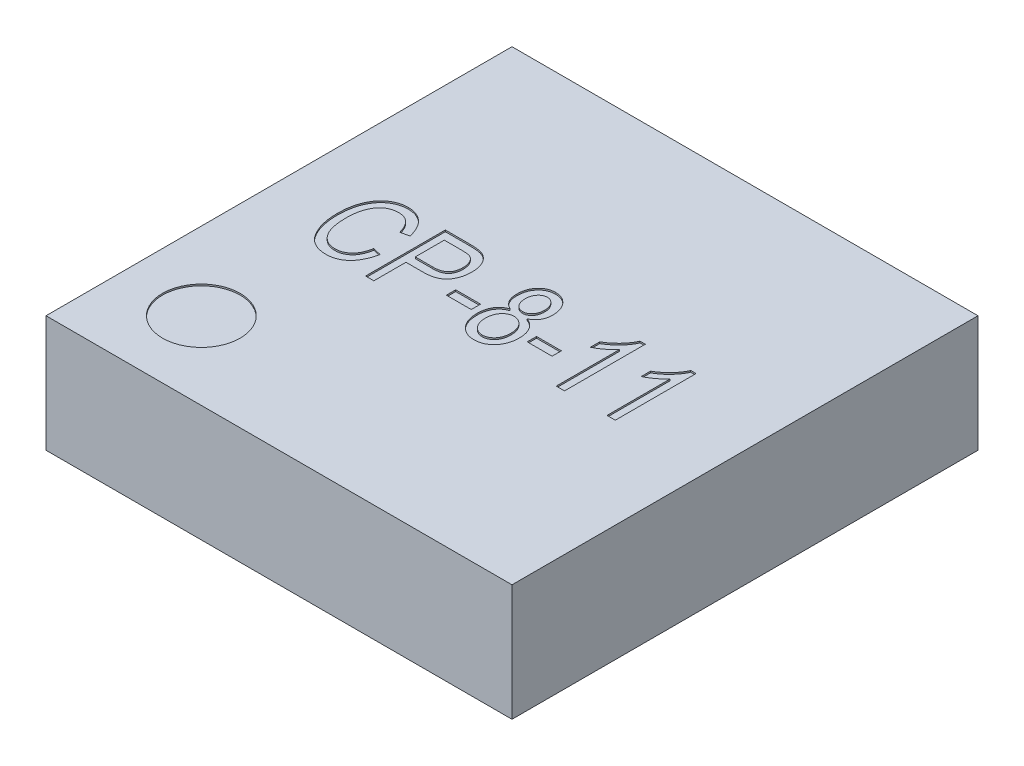
from build123d import *

# Parameters (mm, degrees)
SKETCH1_W           = 3
SKETCH1_H           = 3
BOSS_EXTRUDE1_DEPTH = 0.75
SKETCH2_R           = 0.25
CUT_EXTRUDE1_DEPTH  = 0.01
SKETCH5_W           = 0.160102983
SKETCH5_H           = 0.060038619
CUT_EXTRUDE3_DEPTH  = 0.01


with BuildPart() as part:
    # Sketch1 → Boss-Extrude1 (new body)
    with BuildSketch(Plane(origin=(0, 0, 0), x_dir=(1, 0, 0), z_dir=(0, 1, 0))):
        Rectangle(SKETCH1_W, SKETCH1_H)
    extrude(amount=BOSS_EXTRUDE1_DEPTH)

    # Sketch2 → Cut-Extrude1 (cut)
    with BuildSketch(Plane(origin=(0, 0.75, 0), x_dir=(1, 0, 0), z_dir=(0, 1, 0))):
        with Locations(Location((-1, -1, 0), (0, 0, 270))):
            Circle(SKETCH2_R)
    extrude(amount=-CUT_EXTRUDE1_DEPTH, mode=Mode.SUBTRACT)

    # Sketch5 → Cut-Extrude3 (cut)
    with BuildSketch(Plane(origin=(0, 0.75, 0), x_dir=(1, 0, 0), z_dir=(0, 1, 0))):
        with BuildLine():
            Line((-0.819562322, -0.069884144), (-0.766194661, -0.083226059))
            add(Edge.make_bspline(
                [(-0.766194661, -0.083226059), (-0.767785294, -0.090298254), (-0.770886363, -0.104086083), (-0.776702946, -0.123917486), (-0.783499751, -0.142322568), (-0.791090653, -0.159371055), (-0.799536523, -0.175065562), (-0.808795785, -0.189395293), (-0.818946382, -0.202348536), (-0.830038875, -0.213765782), (-0.841702978, -0.224010076), (-0.85421037, -0.232609166), (-0.86718476, -0.240145481), (-0.880874045, -0.246147831), (-0.895140051, -0.250901973), (-0.91005958, -0.254181603), (-0.925572015, -0.256379357), (-0.936157368, -0.256572956), (-0.941515766, -0.256670958)],
                knots=[0, 0, 0, 0, 1.289221957, 2.51344498, 3.673011535, 4.776835723, 5.830430132, 6.840130389, 7.808269491, 8.7523986, 9.668123701, 10.564817631, 11.447926293, 12.333367568, 13.218722559, 14.118350969, 15.047492789, 16, 16, 16, 16], degree=3))
            add(Edge.make_bspline(
                [(-0.941515766, -0.256670958), (-0.946245001, -0.256605701), (-0.955515411, -0.256477783), (-0.969158098, -0.255031745), (-0.982309097, -0.252919536), (-0.994937963, -0.249739562), (-1.007072515, -0.24584663), (-1.018595594, -0.240846974), (-1.029694441, -0.235157022), (-1.040242021, -0.228432663), (-1.050363647, -0.220814832), (-1.059787685, -0.211957525), (-1.068969987, -0.20227548), (-1.077440003, -0.191306057), (-1.085772683, -0.179486592), (-1.093263877, -0.166375155), (-1.100531229, -0.152355342), (-1.107223863, -0.137314422), (-1.113457604, -0.121403643), (-1.118548257, -0.104599383), (-1.123088544, -0.087194103), (-1.126691944, -0.069052902), (-1.129665056, -0.05025115), (-1.131547806, -0.030686803), (-1.132878496, -0.010454576), (-1.13302357, 0.003285615), (-1.133097331, 0.010271581)],
                knots=[0, 0, 0, 0, 0.921095259, 1.805562833, 2.670327692, 3.514278933, 4.340642213, 5.150451062, 5.958900505, 6.768369716, 7.58482939, 8.423223242, 9.285360719, 10.181948201, 11.120907027, 12.10087379, 13.121233649, 14.196976745, 15.307105309, 16.44839936, 17.61583717, 18.810746038, 20.050660639, 21.323136918, 22.638994396, 24, 24, 24, 24], degree=3))
            add(Edge.make_bspline(
                [(-1.133097331, 0.010271581), (-1.133024173, 0.017153383), (-1.132880687, 0.030650741), (-1.131552175, 0.05046653), (-1.129674216, 0.069512125), (-1.126690629, 0.087722158), (-1.123111878, 0.105175868), (-1.118588539, 0.121757099), (-1.11342171, 0.137602263), (-1.10727773, 0.152559829), (-1.100354257, 0.166641718), (-1.092955946, 0.179906524), (-1.085065647, 0.192355451), (-1.076502762, 0.203860971), (-1.067313005, 0.214394517), (-1.057570963, 0.224061575), (-1.047226048, 0.232802019), (-1.036397959, 0.240774009), (-1.02505111, 0.247683272), (-1.01341952, 0.253819084), (-1.001415684, 0.258910155), (-0.989083411, 0.263093701), (-0.976434622, 0.266345693), (-0.96346455, 0.268581594), (-0.950205858, 0.270158631), (-0.941242525, 0.27027566), (-0.936721016, 0.270334695)],
                knots=[0, 0, 0, 0, 1.355009242, 2.657595594, 3.909622363, 5.12221665, 6.289669639, 7.416642245, 8.504963989, 9.569716403, 10.597874851, 11.593392335, 12.559484071, 13.498222117, 14.414780627, 15.309839368, 16.198178116, 17.079506653, 17.954919271, 18.811820418, 19.667108407, 20.519600343, 21.37423126, 22.235899437, 23.110108003, 24, 24, 24, 24], degree=3))
            add(Edge.make_bspline(
                [(-0.936721016, 0.270334695), (-0.931782876, 0.270206847), (-0.922082694, 0.269955711), (-0.907755076, 0.268197066), (-0.894049104, 0.2649985), (-0.880734222, 0.260877676), (-0.868060298, 0.255307035), (-0.85586358, 0.248605142), (-0.844250446, 0.240630738), (-0.833213313, 0.23143294), (-0.822764165, 0.221125603), (-0.81313969, 0.20960075), (-0.804427749, 0.196909476), (-0.796289764, 0.183229479), (-0.789280602, 0.168227328), (-0.7829609, 0.15216685), (-0.777206964, 0.135020621), (-0.774337034, 0.123043399), (-0.772865619, 0.116902669)],
                knots=[0, 0, 0, 0, 0.969230344, 1.90389736, 2.827024372, 3.728538081, 4.635631584, 5.539103428, 6.456494714, 7.396000419, 8.355610671, 9.333534695, 10.338037519, 11.374284513, 12.454112223, 13.583699076, 14.761161004, 16, 16, 16, 16], degree=3))
            Line((-0.772865619, 0.116902669), (-0.82623328, 0.103560754))
            add(Edge.make_bspline(
                [(-0.82623328, 0.103560754), (-0.827439498, 0.107882608), (-0.829791985, 0.116311523), (-0.833978303, 0.128418013), (-0.838556982, 0.139697907), (-0.843533126, 0.150181656), (-0.849074465, 0.159778289), (-0.855019042, 0.168566011), (-0.86137703, 0.176569284), (-0.868281976, 0.183619353), (-0.875504072, 0.189980484), (-0.883264627, 0.195429784), (-0.891499204, 0.19998217), (-0.900133395, 0.203809004), (-0.909194482, 0.206687466), (-0.918712261, 0.208807665), (-0.928661435, 0.210058267), (-0.935466728, 0.210216179), (-0.938909924, 0.210296076)],
                knots=[0, 0, 0, 0, 1.274827499, 2.486296693, 3.637698816, 4.732866786, 5.781146847, 6.783409552, 7.745577291, 8.681189198, 9.583979081, 10.476943643, 11.369744444, 12.253932728, 13.156290603, 14.066553906, 15.021756508, 16, 16, 16, 16], degree=3))
            add(Edge.make_bspline(
                [(-0.938909924, 0.210296076), (-0.945706113, 0.210044284), (-0.958967845, 0.20955295), (-0.978148328, 0.205465966), (-0.995994685, 0.19892868), (-1.00957763, 0.191084332), (-1.019648576, 0.18356043), (-1.026787039, 0.177128071), (-1.033508527, 0.169947158), (-1.039894865, 0.162086071), (-1.045944345, 0.153480514), (-1.051399698, 0.144025722), (-1.05669042, 0.133989925), (-1.061457926, 0.123158901), (-1.065705133, 0.111592205), (-1.069482771, 0.099314869), (-1.072704686, 0.086305165), (-1.075303635, 0.072523495), (-1.077236038, 0.058008824), (-1.07872591, 0.042749213), (-1.07952591, 0.026749103), (-1.079660916, 0.015831496), (-1.07972967, 0.010271581)],
                knots=[0, 0, 0, 0, 1.477189771, 2.882511776, 4.245778241, 5.596752156, 6.277022015, 6.978177212, 7.684002091, 8.414723124, 9.180080371, 9.969542299, 10.787683758, 11.647234596, 12.541638645, 13.466905688, 14.440346501, 15.45581228, 16.516221105, 17.624831929, 18.790418795, 20, 20, 20, 20], degree=3))
            add(Edge.make_bspline(
                [(-1.07972967, 0.010271581), (-1.079597837, 0.001930269), (-1.079342139, -0.014248321), (-1.077711704, -0.037744912), (-1.074859166, -0.059657866), (-1.070671638, -0.079914137), (-1.065499151, -0.098578906), (-1.059206021, -0.115659314), (-1.0515537, -0.13108365), (-1.042811289, -0.144883999), (-1.033056819, -0.157050404), (-1.022532334, -0.167650607), (-1.011171414, -0.176576314), (-0.999112043, -0.183997784), (-0.986174661, -0.189611283), (-0.972540921, -0.193717459), (-0.958106251, -0.196153283), (-0.94823078, -0.196470309), (-0.943183506, -0.196632339)],
                knots=[0, 0, 0, 0, 1.437104972, 2.787371166, 4.055570009, 5.241294904, 6.348053785, 7.389870239, 8.372351441, 9.308936623, 10.198930124, 11.053953419, 11.87666206, 12.682560998, 13.486679433, 14.299132302, 15.130700221, 16, 16, 16, 16], degree=3))
            add(Edge.make_bspline(
                [(-0.943183506, -0.196632339), (-0.939425994, -0.196528996), (-0.932021406, -0.196325347), (-0.921105015, -0.194804129), (-0.910545955, -0.192451887), (-0.90037098, -0.188999631), (-0.890689676, -0.184449319), (-0.881306686, -0.179151576), (-0.87241586, -0.172695918), (-0.863892883, -0.16535142), (-0.855913064, -0.156951235), (-0.848618087, -0.147504172), (-0.841897901, -0.137087218), (-0.836132852, -0.125528209), (-0.830890515, -0.113069368), (-0.826314247, -0.099595857), (-0.822450941, -0.085107751), (-0.820540679, -0.075040282), (-0.819562322, -0.069884144)],
                knots=[0, 0, 0, 0, 0.928044623, 1.828813311, 2.717973564, 3.597468745, 4.476963925, 5.35746386, 6.25552913, 7.186585864, 8.133765821, 9.112470931, 10.131597503, 11.191133367, 12.299110282, 13.469062082, 14.703759174, 16, 16, 16, 16], degree=3))
        make_face()
        with BuildLine():
            Line((-0.692814128, -0.25), (-0.692814128, 0.263663737))
            Line((-0.692814128, 0.263663737), (-0.534587351, 0.263663737))
            add(Edge.make_bspline(
                [(-0.534587351, 0.263663737), (-0.530069601, 0.263667976), (-0.521378123, 0.263676132), (-0.508802339, 0.263060869), (-0.497110496, 0.262439162), (-0.486343609, 0.26123954), (-0.476493529, 0.259929597), (-0.467570318, 0.258292664), (-0.459572194, 0.256223859), (-0.454597101, 0.254552485), (-0.452242718, 0.253761534)],
                knots=[0, 0, 0, 0, 1.301145482, 2.503209419, 3.626350361, 4.67304202, 5.622796861, 6.488461115, 7.284688674, 8, 8, 8, 8], degree=3))
            add(Edge.make_bspline(
                [(-0.452242718, 0.253761534), (-0.44926147, 0.252607629), (-0.443306037, 0.250302552), (-0.434917469, 0.245751859), (-0.426915349, 0.240625047), (-0.419390368, 0.234788548), (-0.412386658, 0.228152405), (-0.40579459, 0.220862428), (-0.399745133, 0.212768753), (-0.394171393, 0.204043766), (-0.388981379, 0.194775492), (-0.384696175, 0.184850595), (-0.380846787, 0.174478327), (-0.37791799, 0.163537202), (-0.375442878, 0.152104614), (-0.373866427, 0.140145913), (-0.372742828, 0.127660182), (-0.372653733, 0.119163794), (-0.372608162, 0.114817995)],
                knots=[0, 0, 0, 0, 0.897158766, 1.79219156, 2.674738776, 3.564969572, 4.462552928, 5.381685756, 6.322532571, 7.297145314, 8.28871417, 9.302465757, 10.330585605, 11.393732126, 12.480975679, 13.614163778, 14.779673607, 16, 16, 16, 16], degree=3))
            add(Edge.make_bspline(
                [(-0.372608162, 0.114817995), (-0.372696397, 0.109115783), (-0.372868965, 0.097963593), (-0.374563313, 0.081652153), (-0.377379265, 0.066186591), (-0.381221332, 0.05149261), (-0.386211164, 0.037592399), (-0.392389974, 0.024522487), (-0.399638444, 0.012236066), (-0.407913616, 0.000710211), (-0.417665111, -0.009781098), (-0.429173782, -0.018756336), (-0.442194822, -0.026432521), (-0.45689078, -0.032533888), (-0.473111749, -0.037462143), (-0.491004785, -0.040821802), (-0.510500753, -0.042767667), (-0.524020345, -0.043052402), (-0.531043405, -0.043200314)],
                knots=[0, 0, 0, 0, 1.066125632, 2.085091685, 3.062630143, 4.003547869, 4.922307223, 5.820454748, 6.703048758, 7.586837887, 8.469431897, 9.371589709, 10.306565591, 11.287746888, 12.340181319, 13.471797101, 14.68666727, 16, 16, 16, 16], degree=3))
            Line((-0.531043405, -0.043200314), (-0.639446467, -0.043200314))
            Line((-0.639446467, -0.043200314), (-0.639446467, -0.25))
            Line((-0.639446467, -0.25), (-0.692814128, -0.25))
        make_face()
        with BuildLine():
            Line((-0.639446467, 0.016838305), (-0.527707926, 0.016838305))
            add(Edge.make_bspline(
                [(-0.527707926, 0.016838305), (-0.523467507, 0.016933574), (-0.515251648, 0.017118158), (-0.503326673, 0.01810269), (-0.492280679, 0.019980416), (-0.482117246, 0.022551845), (-0.472864666, 0.025904995), (-0.464476781, 0.02993703), (-0.457001483, 0.034790043), (-0.450321013, 0.040337016), (-0.444627221, 0.046781983), (-0.439505402, 0.053802467), (-0.435351732, 0.061729966), (-0.43195731, 0.070376369), (-0.429200101, 0.079713485), (-0.427380875, 0.089813797), (-0.426218043, 0.100649802), (-0.426058167, 0.108143857), (-0.425975823, 0.112003685)],
                knots=[0, 0, 0, 0, 1.269306236, 2.459294321, 3.577321076, 4.618943517, 5.592639886, 6.518111891, 7.397820391, 8.253919533, 9.107995395, 9.965041305, 10.848919063, 11.777714976, 12.741869721, 13.757527659, 14.845010431, 16, 16, 16, 16], degree=3))
            add(Edge.make_bspline(
                [(-0.425975823, 0.112003685), (-0.426094373, 0.117017315), (-0.426323775, 0.126718978), (-0.428696642, 0.140673852), (-0.432367221, 0.153546898), (-0.437739352, 0.165079173), (-0.444021996, 0.175191851), (-0.450901449, 0.183842516), (-0.458584935, 0.190638882), (-0.465735721, 0.194874882), (-0.472015677, 0.197546439), (-0.477611972, 0.199195078), (-0.484074088, 0.200490041), (-0.4913787, 0.201624028), (-0.49951158, 0.202580201), (-0.508488246, 0.203143554), (-0.518322136, 0.203605847), (-0.525170902, 0.203618503), (-0.528750264, 0.203625118)],
                knots=[0, 0, 0, 0, 1.500314686, 2.903195123, 4.226916567, 5.498136997, 6.699407891, 7.786731959, 8.797026544, 9.75363827, 10.261964553, 10.838097333, 11.497334866, 12.234733717, 13.051831226, 13.948971176, 14.928073425, 16, 16, 16, 16], degree=3))
            Line((-0.528750264, 0.203625118), (-0.639446467, 0.203625118))
            Line((-0.639446467, 0.203625118), (-0.639446467, 0.016838305))
        make_face(mode=Mode.SUBTRACT)
        with Locations((-0.245859967, -0.066548665)):
            Rectangle(SKETCH5_W, SKETCH5_H)
        with BuildLine():
            add(Edge.make_bspline(
                [(-0.043333863, 0.03184796), (-0.048244191, 0.034315549), (-0.057824326, 0.039129858), (-0.070593555, 0.048559692), (-0.081481963, 0.059510796), (-0.09045116, 0.072062053), (-0.097390633, 0.086225699), (-0.102215422, 0.101952005), (-0.10535262, 0.11921048), (-0.105627167, 0.131272172), (-0.105769857, 0.137540944)],
                knots=[0, 0, 0, 0, 1.008302473, 1.967215395, 2.901654035, 3.835241807, 4.788827276, 5.786238528, 6.849451133, 8, 8, 8, 8], degree=3))
            add(Edge.make_bspline(
                [(-0.105769857, 0.137540944), (-0.1056743, 0.142339941), (-0.1054875, 0.151721268), (-0.103893199, 0.165461026), (-0.101274719, 0.178486042), (-0.097808052, 0.190892056), (-0.093012142, 0.202490323), (-0.087420075, 0.213555058), (-0.080594864, 0.223840095), (-0.07292235, 0.233438967), (-0.064407353, 0.242038785), (-0.05530628, 0.249598115), (-0.045648399, 0.25603634), (-0.035413013, 0.261226696), (-0.024694255, 0.265335322), (-0.013449479, 0.268295765), (-0.001653462, 0.269926313), (0.006380954, 0.270197385), (0.010450733, 0.270334695)],
                knots=[0, 0, 0, 0, 1.165528948, 2.278436123, 3.35437051, 4.390847764, 5.401785756, 6.398351761, 7.397951243, 8.394481506, 9.379254266, 10.332413116, 11.264104055, 12.192693114, 13.114390379, 14.047914605, 15.011184464, 16, 16, 16, 16], degree=3))
            add(Edge.make_bspline(
                [(0.010450733, 0.270334695), (0.014556848, 0.270209136), (0.022668578, 0.269961093), (0.034549433, 0.268159785), (0.045903617, 0.265231238), (0.056731248, 0.261161008), (0.067015039, 0.255800692), (0.07668879, 0.249201227), (0.085872332, 0.241484791), (0.094443173, 0.232701684), (0.10222242, 0.222952747), (0.109003342, 0.212449218), (0.114934459, 0.201381204), (0.119596868, 0.189504019), (0.123258317, 0.176943318), (0.125824876, 0.163683864), (0.127430097, 0.149775798), (0.127617935, 0.140290228), (0.12771366, 0.13545627)],
                knots=[0, 0, 0, 0, 0.985268531, 1.946421878, 2.87680472, 3.795226773, 4.71648376, 5.65319809, 6.600248485, 7.590936614, 8.593729089, 9.588305238, 10.588007114, 11.602279753, 12.644649782, 13.724021809, 14.840134863, 16, 16, 16, 16], degree=3))
            add(Edge.make_bspline(
                [(0.12771366, 0.13545627), (0.127561336, 0.129431324), (0.12726792, 0.117825637), (0.124241646, 0.101158347), (0.119530444, 0.085877807), (0.112671033, 0.07207018), (0.103902812, 0.059663636), (0.093134777, 0.048779631), (0.080475046, 0.039175288), (0.070856779, 0.034338868), (0.065903068, 0.03184796)],
                knots=[0, 0, 0, 0, 1.126288406, 2.16953834, 3.158564267, 4.109347243, 5.041996175, 5.989081932, 6.964313779, 8, 8, 8, 8], degree=3))
            add(Edge.make_bspline(
                [(0.065903068, 0.03184796), (0.069123331, 0.030545264), (0.075500175, 0.027965633), (0.084530664, 0.023233081), (0.093049947, 0.018047429), (0.100870074, 0.012143924), (0.108224891, 0.005775054), (0.115017752, -0.001211453), (0.121166066, -0.008837204), (0.126679708, -0.017030002), (0.13176814, -0.025669413), (0.135952969, -0.034973246), (0.13967402, -0.04469225), (0.142547409, -0.054963566), (0.144850426, -0.065720602), (0.146480178, -0.076968353), (0.14758979, -0.088728265), (0.147680221, -0.096739001), (0.147726533, -0.100841557)],
                knots=[0, 0, 0, 0, 0.998518868, 1.977292132, 2.928488769, 3.863806314, 4.791620617, 5.724425947, 6.662355446, 7.604692757, 8.562792825, 9.541974082, 10.534927333, 11.553397264, 12.605860047, 13.696849039, 14.820482036, 16, 16, 16, 16], degree=3))
            add(Edge.make_bspline(
                [(0.147726533, -0.100841557), (0.147597656, -0.106439144), (0.147344844, -0.117419732), (0.145620648, -0.133515805), (0.142423465, -0.148799699), (0.138217927, -0.163349135), (0.132638897, -0.17704229), (0.125960489, -0.190013443), (0.117888169, -0.202087556), (0.108738405, -0.21332027), (0.098736347, -0.223465918), (0.087991041, -0.232307892), (0.076704809, -0.239864626), (0.064773794, -0.246091855), (0.052166392, -0.25072222), (0.039068408, -0.254254607), (0.025344929, -0.25620463), (0.01601549, -0.256514052), (0.011284603, -0.256670958)],
                knots=[0, 0, 0, 0, 1.159749967, 2.275040396, 3.347967098, 4.391166783, 5.408413163, 6.406504519, 7.408740576, 8.411571025, 9.404143995, 10.355316395, 11.289670068, 12.213679047, 13.136228826, 14.066859406, 15.019719104, 16, 16, 16, 16], degree=3))
            add(Edge.make_bspline(
                [(0.011284603, -0.256670958), (0.006484038, -0.256515792), (-0.00294974, -0.256210871), (-0.016808989, -0.254250347), (-0.029987134, -0.25074596), (-0.04264043, -0.246061346), (-0.054643039, -0.239902179), (-0.065946963, -0.232269316), (-0.076793065, -0.223507314), (-0.086777005, -0.213306357), (-0.096001588, -0.202112947), (-0.103867121, -0.189838686), (-0.110756227, -0.176844165), (-0.116247455, -0.162918711), (-0.120540071, -0.148157126), (-0.123506143, -0.132518492), (-0.125446659, -0.116073635), (-0.125669312, -0.104808121), (-0.12578273, -0.099069584)],
                knots=[0, 0, 0, 0, 0.984972937, 1.935608695, 2.864070717, 3.777636659, 4.698984135, 5.624239024, 6.571662262, 7.554569506, 8.54763434, 9.542156389, 10.540146702, 11.560717074, 12.60743999, 13.689489912, 14.823049757, 16, 16, 16, 16], degree=3))
            add(Edge.make_bspline(
                [(-0.12578273, -0.099069584), (-0.125732326, -0.094863337), (-0.125633436, -0.086610942), (-0.124572233, -0.074492767), (-0.122803367, -0.062938861), (-0.120415532, -0.051967649), (-0.117403269, -0.041568529), (-0.113642898, -0.031734336), (-0.10916736, -0.022465356), (-0.104021066, -0.013763294), (-0.098327971, -0.005657086), (-0.092058512, 0.001782765), (-0.085229458, 0.008488804), (-0.077903265, 0.014548832), (-0.070068297, 0.020035014), (-0.061617323, 0.024671741), (-0.052694536, 0.028694039), (-0.046480575, 0.030787728), (-0.043333863, 0.03184796)],
                knots=[0, 0, 0, 0, 1.21084686, 2.375606163, 3.49898943, 4.574306622, 5.606312177, 6.613285576, 7.602106595, 8.566331322, 9.521116698, 10.451051306, 11.363604456, 12.273026677, 13.186018397, 14.112988761, 15.044428814, 16, 16, 16, 16], degree=3))
        make_face()
        with BuildLine():
            add(Edge.make_bspline(
                [(-0.052402196, 0.139000216), (-0.052201804, 0.133041663), (-0.051818369, 0.121640424), (-0.048377114, 0.105430532), (-0.042515869, 0.091151104), (-0.034492799, 0.078937385), (-0.024677728, 0.069244205), (-0.013730649, 0.061966633), (-0.001538943, 0.057592086), (0.006976754, 0.057108622), (0.011284603, 0.056864051)],
                knots=[0, 0, 0, 0, 1.231806288, 2.356967922, 3.407623546, 4.408504678, 5.359070988, 6.242373184, 7.110866593, 8, 8, 8, 8], degree=3))
            add(Edge.make_bspline(
                [(0.011284603, 0.056864051), (0.015526973, 0.057103254), (0.023915227, 0.057576219), (0.035845253, 0.062031617), (0.046771762, 0.068999326), (0.056364175, 0.078640372), (0.064392134, 0.090427593), (0.070274495, 0.104067195), (0.073751009, 0.11933652), (0.074142717, 0.130017485), (0.074345999, 0.135560504)],
                knots=[0, 0, 0, 0, 0.904069307, 1.787576968, 2.686104763, 3.657927982, 4.673759711, 5.718490521, 6.815982417, 8, 8, 8, 8], degree=3))
            add(Edge.make_bspline(
                [(0.074345999, 0.135560504), (0.07415062, 0.141278224), (0.073773578, 0.152312285), (0.070192432, 0.168029507), (0.064189449, 0.182126847), (0.055831765, 0.19421143), (0.046094053, 0.204258458), (0.035122943, 0.211559076), (0.023200023, 0.216146562), (0.01486832, 0.216691656), (0.0106592, 0.216967034)],
                knots=[0, 0, 0, 0, 1.195037322, 2.306184118, 3.351541185, 4.382027117, 5.363972266, 6.261309376, 7.121625266, 8, 8, 8, 8], degree=3))
            add(Edge.make_bspline(
                [(0.0106592, 0.216967034), (0.00645279, 0.216725274), (-0.00186542, 0.216247194), (-0.013779459, 0.211802849), (-0.024638328, 0.204570642), (-0.034243897, 0.194794536), (-0.042448563, 0.183095769), (-0.048127729, 0.169577874), (-0.051852, 0.15476512), (-0.052214617, 0.144374973), (-0.052402196, 0.139000216)],
                knots=[0, 0, 0, 0, 0.904281018, 1.788222997, 2.702503877, 3.698439792, 4.727116192, 5.763971808, 6.843317031, 8, 8, 8, 8], degree=3))
        make_face(mode=Mode.SUBTRACT)
        with BuildLine():
            add(Edge.make_bspline(
                [(-0.072415069, -0.098861116), (-0.07233141, -0.102686187), (-0.072167511, -0.110180019), (-0.070992928, -0.121117039), (-0.069179714, -0.131492292), (-0.066414839, -0.141238885), (-0.063002971, -0.150478411), (-0.058721869, -0.159131692), (-0.053663909, -0.167205731), (-0.048013168, -0.174708938), (-0.04162816, -0.181281706), (-0.035044035, -0.18722951), (-0.028105076, -0.192226369), (-0.020778307, -0.19625743), (-0.013175088, -0.199355601), (-0.005297786, -0.201698711), (0.002896059, -0.203092324), (0.008464979, -0.203232383), (0.011284603, -0.203303297)],
                knots=[0, 0, 0, 0, 1.229957658, 2.409653497, 3.534020377, 4.613053928, 5.663236106, 6.697665706, 7.711552779, 8.723960985, 9.711901018, 10.6537745, 11.574735704, 12.45493582, 13.336836533, 14.210201145, 15.093799183, 16, 16, 16, 16], degree=3))
            add(Edge.make_bspline(
                [(0.011284603, -0.203303297), (0.014140149, -0.203237873), (0.019746144, -0.203109434), (0.02798288, -0.201651629), (0.035895227, -0.199513569), (0.043470012, -0.196437155), (0.050731304, -0.192566975), (0.057607171, -0.18775252), (0.064125821, -0.182013272), (0.070346871, -0.175552234), (0.075897927, -0.168217352), (0.081028573, -0.160447077), (0.08498438, -0.151878322), (0.088541906, -0.142909315), (0.091038302, -0.133228807), (0.093126557, -0.123018454), (0.09406079, -0.11215049), (0.094258097, -0.10473387), (0.094358872, -0.100945791)],
                knots=[0, 0, 0, 0, 0.929108295, 1.824020855, 2.716353585, 3.594799272, 4.480866403, 5.391315445, 6.321801218, 7.306391719, 8.306918377, 9.31465165, 10.332061206, 11.374528197, 12.453461109, 13.583192095, 14.765602254, 16, 16, 16, 16], degree=3))
            add(Edge.make_bspline(
                [(0.094358872, -0.100945791), (0.094271715, -0.097121376), (0.094100964, -0.089628829), (0.092974746, -0.078676257), (0.09098556, -0.06832748), (0.088264445, -0.058565847), (0.084836396, -0.049330716), (0.080567717, -0.040651959), (0.075435233, -0.03259929), (0.069567293, -0.02522722), (0.063297325, -0.018489014), (0.056605393, -0.012599654), (0.049556403, -0.00768013), (0.04225405, -0.003551083), (0.034595104, -0.000456709), (0.026688882, 0.001907271), (0.018420959, 0.003282785), (0.012783611, 0.003424595), (0.009929565, 0.00349639)],
                knots=[0, 0, 0, 0, 1.22586307, 2.401631645, 3.524301147, 4.599742544, 5.646428614, 6.677414549, 7.693861764, 8.700930997, 9.693673486, 10.640764112, 11.552218418, 12.444626848, 13.323591672, 14.194048812, 15.08569251, 16, 16, 16, 16], degree=3))
            add(Edge.make_bspline(
                [(0.009929565, 0.00349639), (0.007110581, 0.003423734), (0.001542927, 0.003280236), (-0.006627187, 0.001917338), (-0.014396298, -0.000490418), (-0.021988374, -0.003391689), (-0.029081229, -0.007625674), (-0.036018711, -0.012457159), (-0.042461139, -0.018398006), (-0.048604921, -0.025022808), (-0.05419037, -0.032387824), (-0.059130147, -0.040318544), (-0.063196637, -0.048832544), (-0.06650593, -0.057853084), (-0.069267412, -0.067341228), (-0.071124573, -0.077396235), (-0.072132385, -0.087965323), (-0.072319464, -0.095176131), (-0.072415069, -0.098861116)],
                knots=[0, 0, 0, 0, 0.923472587, 1.823911596, 2.703001348, 3.586871794, 4.479500873, 5.402130619, 6.35347509, 7.344669241, 8.360414412, 9.377945173, 10.401637647, 11.446516964, 12.524200813, 13.636404357, 14.792116778, 16, 16, 16, 16], degree=3))
        make_face(mode=Mode.SUBTRACT)
        with Locations((0.274474728, -0.066548665)):
            Rectangle(SKETCH5_W, SKETCH5_H)
        with BuildLine():
            Line((0.588009736, -0.25), (0.534642075, -0.25))
            Line((0.534642075, -0.25), (0.534642075, 0.156928415))
            add(Edge.make_bspline(
                [(0.534642075, 0.156928415), (0.531364572, 0.153155728), (0.524571951, 0.145336838), (0.512780308, 0.134217287), (0.499639826, 0.122750762), (0.485091567, 0.111624181), (0.470268049, 0.100966718), (0.45562707, 0.091593293), (0.441717368, 0.083437707), (0.432385921, 0.079004769), (0.427906753, 0.076876924)],
                knots=[0, 0, 0, 0, 0.892555828, 1.849821039, 2.893015883, 4.008277588, 5.121255548, 6.154629642, 7.114207698, 8, 8, 8, 8], degree=3))
            Line((0.427906753, 0.076876924), (0.427906753, 0.136915542))
            add(Edge.make_bspline(
                [(0.427906753, 0.136915542), (0.435105137, 0.141247804), (0.449440268, 0.149875231), (0.469525662, 0.164820721), (0.488500074, 0.18095192), (0.505796364, 0.198437848), (0.521283292, 0.216463221), (0.534576079, 0.234452566), (0.545475321, 0.252214748), (0.550821749, 0.26443308), (0.553404143, 0.270334695)],
                knots=[0, 0, 0, 0, 1.082272232, 2.155277244, 3.222407096, 4.289527553, 5.32168536, 6.282742408, 7.170542132, 8, 8, 8, 8], degree=3))
            Line((0.553404143, 0.270334695), (0.588009736, 0.270334695))
            Line((0.588009736, 0.270334695), (0.588009736, -0.25))
        make_face()
        with BuildLine():
            Line((0.91488666, -0.25), (0.861518999, -0.25))
            Line((0.861518999, -0.25), (0.861518999, 0.156928415))
            add(Edge.make_bspline(
                [(0.861518999, 0.156928415), (0.858241496, 0.153155728), (0.851448874, 0.145336838), (0.839657232, 0.134217287), (0.826516749, 0.122750762), (0.81196849, 0.111624181), (0.797144972, 0.100966718), (0.782503994, 0.091593293), (0.768594292, 0.083437707), (0.759262845, 0.079004769), (0.754783677, 0.076876924)],
                knots=[0, 0, 0, 0, 0.892555828, 1.849821039, 2.893015883, 4.008277588, 5.121255548, 6.154629642, 7.114207698, 8, 8, 8, 8], degree=3))
            Line((0.754783677, 0.076876924), (0.754783677, 0.136915542))
            add(Edge.make_bspline(
                [(0.754783677, 0.136915542), (0.761982061, 0.141247804), (0.776317192, 0.149875231), (0.796402586, 0.164820721), (0.815376998, 0.18095192), (0.832673288, 0.198437848), (0.848160216, 0.216463221), (0.861453002, 0.234452566), (0.872352245, 0.252214748), (0.877698672, 0.26443308), (0.880281067, 0.270334695)],
                knots=[0, 0, 0, 0, 1.082272232, 2.155277244, 3.222407096, 4.289527553, 5.32168536, 6.282742408, 7.170542132, 8, 8, 8, 8], degree=3))
            Line((0.880281067, 0.270334695), (0.91488666, 0.270334695))
            Line((0.91488666, 0.270334695), (0.91488666, -0.25))
        make_face()
    extrude(amount=-CUT_EXTRUDE3_DEPTH, mode=Mode.SUBTRACT)


solid = part.part
